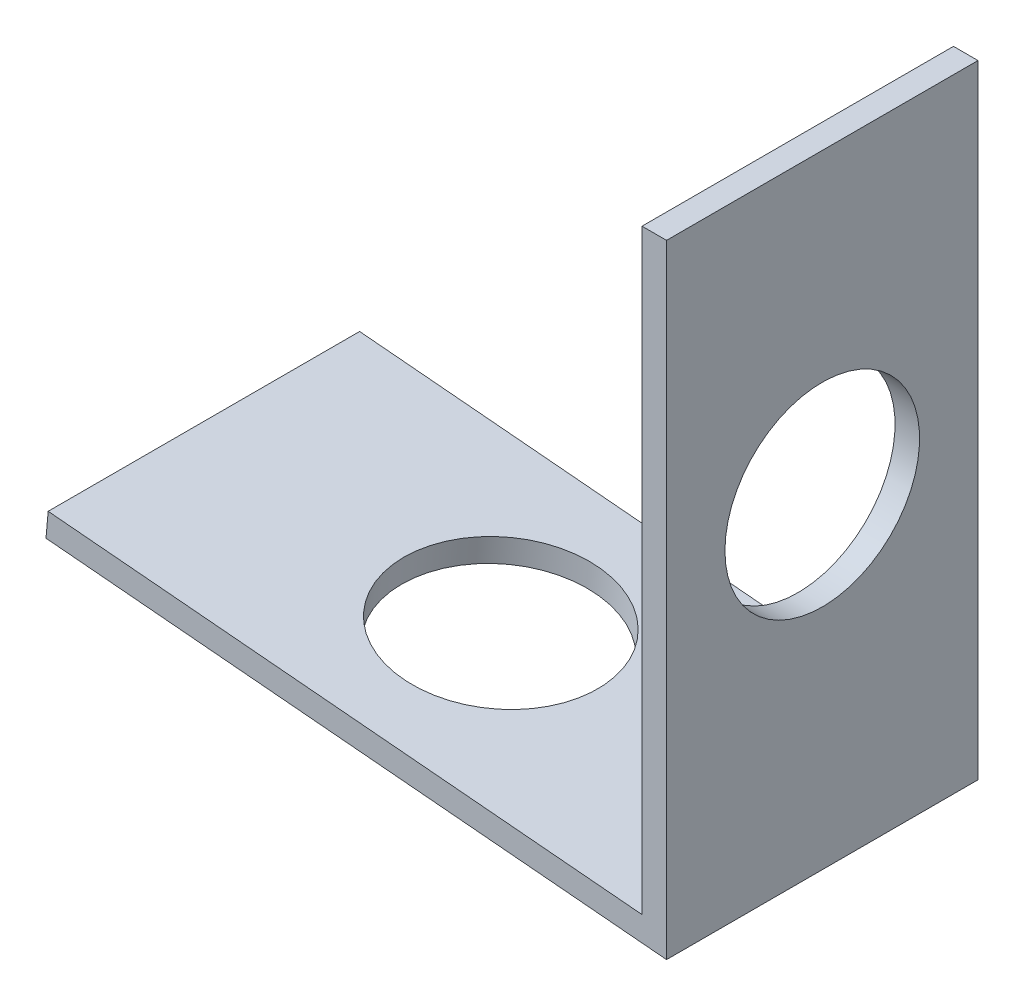
from build123d import *

# Parameters (mm, degrees)
BOSS_EXTRUDE1_DEPTH            = 6.35
F_5_16_0_3125_DIAMETER_HOLE1_D = 7.9375
F_5_16_0_3125_DIAMETER_HOLE2_D = 7.9375


with BuildPart() as part:
    # Sketch1 → Boss-Extrude1 (new body, symmetric)
    with BuildSketch(Plane.XY):
        Polygon((0, 0), (0, 25.4), (-1, 25.4), (-1, 1.091974256), (-25.214234797, 3.225269541), (-25.301995741, 2.229127977), align=None)
    extrude(amount=BOSS_EXTRUDE1_DEPTH, both=True)

    # 5/16 (0.3125) Diameter Hole1 (through all)
    with Locations(Plane(origin=(-1, 13.245987128, 0), x_dir=(0, -1, 0), z_dir=(-1, 0, 0))):
        with Locations((0, 0)):
            Hole(F_5_16_0_3125_DIAMETER_HOLE1_D / 2)

    # 5/16 (0.3125) Diameter Hole2 (through all)
    with Locations(Plane(origin=(-13.107117398, 2.158621899, 0), x_dir=(0.996141565, -0.087760944, 0), z_dir=(0.087760944, 0.996141565, 0))):
        with Locations((0, 0)):
            Hole(F_5_16_0_3125_DIAMETER_HOLE2_D / 2)


solid = part.part
